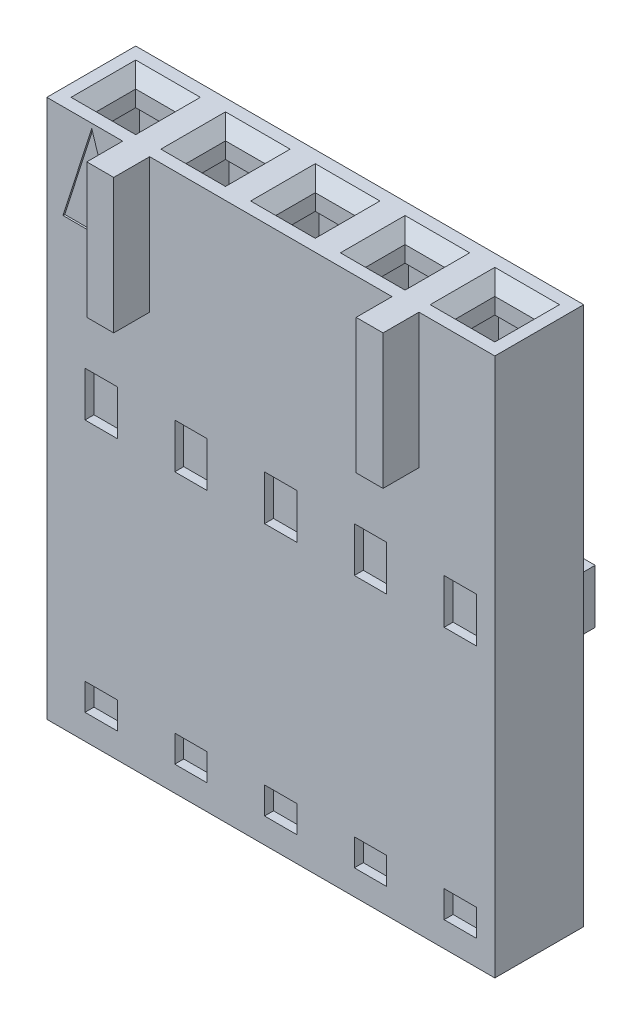
from build123d import *

# Parameters (mm, degrees)
SKETCH1_W            = 12.6746
SKETCH1_H            = 15.24
BOSS_EXTRUDE1_DEPTH  = 2.514600001
SKETCH2_W            = 1.8542
SKETCH2_H            = 1.778
CUT_EXTRUDE1_DEPTH   = 8.636
SKETCH3_W            = 1.8542
SKETCH3_H            = 1.778
CUT_EXTRUDE2_DEPTH   = 8.636
SKETCH4_W            = 1.8542
SKETCH4_H            = 1.778
CUT_EXTRUDE3_DEPTH   = 8.636
SKETCH5_W            = 1.8542
SKETCH5_H            = 1.778
CUT_EXTRUDE4_DEPTH   = 8.636
SKETCH6_W            = 1.8542
SKETCH6_H            = 1.778
CUT_EXTRUDE5_DEPTH   = 8.636
CHAMFER1_SIZE        = 0.0762
CHAMFER1_SIZE2       = 0.254
CHAMFER2_SIZE        = 0.0762
CHAMFER2_SIZE2       = 0.254
CHAMFER3_SIZE        = 0.0762
CHAMFER3_SIZE2       = 0.254
CHAMFER4_SIZE        = 0.0762
CHAMFER4_SIZE2       = 0.254
CHAMFER5_SIZE        = 0.0762
CHAMFER5_SIZE2       = 0.254
CUT_EXTRUDE6_REACH   = 12.213
SKETCH8_W            = 1.4224
SKETCH8_H            = 1.6256
CUT_EXTRUDE7_DEPTH   = 5.7912
SKETCH9_W            = 1.4224
SKETCH9_H            = 1.6256
CUT_EXTRUDE8_DEPTH   = 5.7912
SKETCH10_W           = 1.4224
SKETCH10_H           = 1.6256
CUT_EXTRUDE9_DEPTH   = 5.7912
SKETCH11_W           = 1.4224
SKETCH11_H           = 1.6256
CUT_EXTRUDE10_DEPTH  = 5.7912
SKETCH12_W           = 1.4224
SKETCH12_H           = 1.6256
CUT_EXTRUDE11_DEPTH  = 5.7912
SKETCH13_W           = 1.1176
SKETCH13_H           = 1.1176
CUT_EXTRUDE12_DEPTH  = 16.807791573
SKETCH14_W           = 1.1176
SKETCH14_H           = 1.1176
CUT_EXTRUDE13_DEPTH  = 16.807791573
SKETCH15_W           = 1.1176
SKETCH15_H           = 1.1176
CUT_EXTRUDE14_DEPTH  = 16.807791573
SKETCH16_W           = 1.1176
SKETCH16_H           = 1.1176
CUT_EXTRUDE15_DEPTH  = 16.807791573
SKETCH17_W           = 1.1176
SKETCH17_H           = 1.1176
CUT_EXTRUDE16_DEPTH  = 16.807791573
BOSS_EXTRUDE2_DEPTH  = 4.7498
BOSS_EXTRUDE3_DEPTH  = 1.549215566
CHAMFER6_SIZE        = 3.689417857
CHAMFER6_SIZE2       = 0.617363155
DRAFT1_ANGLE         = 3.38
CUT_EXTRUDE17_REACH  = 13.516
CUT_EXTRUDE18_REACH  = 13.516
CUT_EXTRUDE19_REACH  = 13.384
CUT_EXTRUDE20_REACH  = 13.384
BOSS_EXTRUDE4_REACH  = 13.023
SKETCH24_W           = 2.032
SKETCH24_H           = 0.5588
CUT_EXTRUDE21_DEPTH  = 0.762
CHAMFER7_SIZE        = 0.508
CHAMFER8_SIZE        = 0.508
CHAMFER9_SIZE        = 0.3556
CHAMFER10_SIZE       = 0.3556
CHAMFER11_SIZE       = 0.3556
CHAMFER12_SIZE       = 0.3556
CHAMFER13_SIZE       = 0.3556
FILLET1_R            = 0.8128
DRAFT2_ANGLE         = 43.044366599
SKETCH26_W           = 0.9271
SKETCH26_H           = 3.937
BOSS_EXTRUDE5_DEPTH  = 2.921
SKETCH27_W           = 0.9271
SKETCH27_H           = 3.937
BOSS_EXTRUDE6_DEPTH  = 2.921
BOSS_EXTRUDE7_DEPTH  = 1.2573
BOSS_EXTRUDE8_DEPTH  = 1.2573
SKETCH30_W           = 1.2573
SKETCH30_H           = 0.6858
CUT_EXTRUDE22_DEPTH  = 2.413
SKETCH31_W           = 1.2573
SKETCH31_H           = 0.6858
CUT_EXTRUDE23_DEPTH  = 2.413
CUT_EXTRUDE24_REACH  = 12.801
SKETCH32_W           = 0.9271
SKETCH32_H           = 2.413
CUT_EXTRUDE25_REACH  = 12.801
SKETCH33_W           = 0.9271
SKETCH33_H           = 2.413
DRAFT3_ANGLE         = 14.743562836
DRAFT4_ANGLE         = 14.743562836
CUT_EXTRUDE26_DEPTH  = 2.032
CUT_EXTRUDE27_DEPTH  = 2.032
CUT_EXTRUDE28_DEPTH  = 2.032
SKETCH37_W           = 1.27
SKETCH37_H           = 0.3683
CUT_EXTRUDE29_DEPTH  = 1.016
SKETCH38_W           = 1.27
SKETCH38_H           = 0.3683
CUT_EXTRUDE30_DEPTH  = 1.016
SKETCH39_W           = 1.27
SKETCH39_H           = 0.3683
CUT_EXTRUDE31_DEPTH  = 1.016
SKETCH40_W           = 1.27
SKETCH40_H           = 0.3683
CUT_EXTRUDE32_DEPTH  = 1.016
SKETCH41_W           = 1.27
SKETCH41_H           = 0.3683
CUT_EXTRUDE33_DEPTH  = 1.016
SKETCH42_W           = 0.9144
SKETCH42_H           = 0.762
CUT_EXTRUDE34_DEPTH  = 0.254
SKETCH43_W           = 0.9144
SKETCH43_H           = 0.762
CUT_EXTRUDE35_DEPTH  = 0.254
SKETCH44_W           = 0.9144
SKETCH44_H           = 0.762
CUT_EXTRUDE36_DEPTH  = 0.254
SKETCH45_W           = 0.9144
SKETCH45_H           = 0.762
CUT_EXTRUDE37_DEPTH  = 0.254
SKETCH46_W           = 0.9144
SKETCH46_H           = 0.762
CUT_EXTRUDE38_DEPTH  = 0.254
SKETCH47_W           = 0.9144
SKETCH47_H           = 1.27
CUT_EXTRUDE39_DEPTH  = 0.254
LPATTERN1_COUNT      = 5
LPATTERN1_PITCH      = 2.54
SKETCH48_W           = 0.762
SKETCH48_H           = 3.81
BOSS_EXTRUDE9_DEPTH  = 1.016
SKETCH49_W           = 0.762
SKETCH49_H           = 3.81
BOSS_EXTRUDE10_DEPTH = 1.016


with BuildPart() as part:
    # Sketch1 → Boss-Extrude1 (new body)
    with BuildSketch(Plane(origin=(0, 0, -1.2573), x_dir=(-1, 0, 0), z_dir=(0, 0, -1))):
        Rectangle(SKETCH1_W, SKETCH1_H)
    extrude(amount=-BOSS_EXTRUDE1_DEPTH)

    # Sketch2 → Cut-Extrude1 (cut)
    with BuildSketch(Plane.XZ.offset(7.62)):
        with Locations((5.08, 0)):
            Rectangle(SKETCH2_W, SKETCH2_H)
    extrude(amount=-CUT_EXTRUDE1_DEPTH, mode=Mode.SUBTRACT)

    # Sketch3 → Cut-Extrude2 (cut)
    with BuildSketch(Plane.XZ.offset(7.62)):
        with Locations((2.54, 0)):
            Rectangle(SKETCH3_W, SKETCH3_H)
    extrude(amount=-CUT_EXTRUDE2_DEPTH, mode=Mode.SUBTRACT)

    # Sketch4 → Cut-Extrude3 (cut)
    with BuildSketch(Plane.XZ.offset(7.62)):
        Rectangle(SKETCH4_W, SKETCH4_H)
    extrude(amount=-CUT_EXTRUDE3_DEPTH, mode=Mode.SUBTRACT)

    # Sketch5 → Cut-Extrude4 (cut)
    with BuildSketch(Plane.XZ.offset(7.62)):
        with Locations((-2.54, 0)):
            Rectangle(SKETCH5_W, SKETCH5_H)
    extrude(amount=-CUT_EXTRUDE4_DEPTH, mode=Mode.SUBTRACT)

    # Sketch6 → Cut-Extrude5 (cut)
    with BuildSketch(Plane.XZ.offset(7.62)):
        with Locations((-5.08, 0)):
            Rectangle(SKETCH6_W, SKETCH6_H)
    extrude(amount=-CUT_EXTRUDE5_DEPTH, mode=Mode.SUBTRACT)

    # Chamfer1
    chamfer1_edges = [part.edges().sort_by_distance(p)[0] for p in [
        (5.08, 1.016, -0.889),
        (6.0071, 1.016, 0),
        (4.1529, 1.016, 0),
        (5.08, 1.016, 0.889),
    ]]
    chamfer1_side = [part.faces().sort_by_distance(p)[0] for p in [
        (5.08, 1.016, 0),
    ]]
    chamfer(chamfer1_edges, length=CHAMFER1_SIZE, length2=CHAMFER1_SIZE2, reference=chamfer1_side[0])

    # Chamfer2
    chamfer2_edges = [part.edges().sort_by_distance(p)[0] for p in [
        (2.54, 1.016, -0.889),
        (3.4671, 1.016, 0),
        (1.6129, 1.016, 0),
        (2.54, 1.016, 0.889),
    ]]
    chamfer2_side = [part.faces().sort_by_distance(p)[0] for p in [
        (2.54, 1.016, 0),
    ]]
    chamfer(chamfer2_edges, length=CHAMFER2_SIZE, length2=CHAMFER2_SIZE2, reference=chamfer2_side[0])

    # Chamfer3
    chamfer3_edges = [part.edges().sort_by_distance(p)[0] for p in [
        (0, 1.016, -0.889),
        (0.9271, 1.016, 0),
        (-0.9271, 1.016, 0),
        (0, 1.016, 0.889),
    ]]
    chamfer3_side = [part.faces().sort_by_distance(p)[0] for p in [
        (0, 1.016, 0),
    ]]
    chamfer(chamfer3_edges, length=CHAMFER3_SIZE, length2=CHAMFER3_SIZE2, reference=chamfer3_side[0])

    # Chamfer4
    chamfer4_edges = [part.edges().sort_by_distance(p)[0] for p in [
        (-2.54, 1.016, -0.889),
        (-1.6129, 1.016, 0),
        (-3.4671, 1.016, 0),
        (-2.54, 1.016, 0.889),
    ]]
    chamfer4_side = [part.faces().sort_by_distance(p)[0] for p in [
        (-2.54, 1.016, 0),
    ]]
    chamfer(chamfer4_edges, length=CHAMFER4_SIZE, length2=CHAMFER4_SIZE2, reference=chamfer4_side[0])

    # Chamfer5
    chamfer5_edges = [part.edges().sort_by_distance(p)[0] for p in [
        (-5.08, 1.016, 0.889),
        (-6.0071, 1.016, 0),
        (-4.1529, 1.016, 0),
        (-5.08, 1.016, -0.889),
    ]]
    chamfer5_side = [part.faces().sort_by_distance(p)[0] for p in [
        (-5.08, 1.016, 0),
    ]]
    chamfer(chamfer5_edges, length=CHAMFER5_SIZE, length2=CHAMFER5_SIZE2, reference=chamfer5_side[0])

    # Sketch7 → Cut-Extrude6 (cut, up to next)
    with BuildSketch(Plane(origin=(0, 0, 1.2065), x_dir=(-1, 0, 0), z_dir=(0, 0, -1)), mode=Mode.PRIVATE) as cut_extrude6_sk1:
        Polygon((4.2545, 4.953), (5.8801, 4.953), (5.0673, 7.493), align=None)
    cut_extrude6_tool1 = extrude(cut_extrude6_sk1.sketch, amount=-CUT_EXTRUDE6_REACH, mode=Mode.PRIVATE) & part.part
    add(cut_extrude6_tool1.solids().sort_by_distance((-5.0673, 5.799667, 1.2065))[0], mode=Mode.SUBTRACT)

    # Sketch8 → Cut-Extrude7 (cut)
    with BuildSketch(Plane.XZ.offset(-1.016)):
        with Locations((-5.08, 0)):
            Rectangle(SKETCH8_W, SKETCH8_H)
    extrude(amount=-CUT_EXTRUDE7_DEPTH, mode=Mode.SUBTRACT)

    # Sketch9 → Cut-Extrude8 (cut)
    with BuildSketch(Plane.XZ.offset(-1.016)):
        with Locations((-2.54, 0)):
            Rectangle(SKETCH9_W, SKETCH9_H)
    extrude(amount=-CUT_EXTRUDE8_DEPTH, mode=Mode.SUBTRACT)

    # Sketch10 → Cut-Extrude9 (cut)
    with BuildSketch(Plane.XZ.offset(-1.016)):
        Rectangle(SKETCH10_W, SKETCH10_H)
    extrude(amount=-CUT_EXTRUDE9_DEPTH, mode=Mode.SUBTRACT)

    # Sketch11 → Cut-Extrude10 (cut)
    with BuildSketch(Plane.XZ.offset(-1.016)):
        with Locations((2.54, 0)):
            Rectangle(SKETCH11_W, SKETCH11_H)
    extrude(amount=-CUT_EXTRUDE10_DEPTH, mode=Mode.SUBTRACT)

    # Sketch12 → Cut-Extrude11 (cut)
    with BuildSketch(Plane.XZ.offset(-1.016)):
        with Locations((5.08, 0)):
            Rectangle(SKETCH12_W, SKETCH12_H)
    extrude(amount=-CUT_EXTRUDE11_DEPTH, mode=Mode.SUBTRACT)

    # Sketch13 → Cut-Extrude12 (cut, through all)
    with BuildSketch(Plane.XZ.offset(-6.8072)):
        with Locations((-5.08, 0)):
            Rectangle(SKETCH13_W, SKETCH13_H)
    extrude(amount=-CUT_EXTRUDE12_DEPTH, mode=Mode.SUBTRACT)

    # Sketch14 → Cut-Extrude13 (cut, through all)
    with BuildSketch(Plane.XZ.offset(-6.8072)):
        with Locations((-2.54, 0)):
            Rectangle(SKETCH14_W, SKETCH14_H)
    extrude(amount=-CUT_EXTRUDE13_DEPTH, mode=Mode.SUBTRACT)

    # Sketch15 → Cut-Extrude14 (cut, through all)
    with BuildSketch(Plane.XZ.offset(-6.8072)):
        Rectangle(SKETCH15_W, SKETCH15_H)
    extrude(amount=-CUT_EXTRUDE14_DEPTH, mode=Mode.SUBTRACT)

    # Sketch16 → Cut-Extrude15 (cut, through all)
    with BuildSketch(Plane.XZ.offset(-6.8072)):
        with Locations((2.54, 0)):
            Rectangle(SKETCH16_W, SKETCH16_H)
    extrude(amount=-CUT_EXTRUDE15_DEPTH, mode=Mode.SUBTRACT)

    # Sketch17 → Cut-Extrude16 (cut, through all)
    with BuildSketch(Plane.XZ.offset(-6.8072)):
        with Locations((5.08, 0)):
            Rectangle(SKETCH17_W, SKETCH17_H)
    extrude(amount=-CUT_EXTRUDE16_DEPTH, mode=Mode.SUBTRACT)

    # Sketch18 → Boss-Extrude2 (add)
    with BuildSketch(Plane(origin=(2.3749, 0, 0), x_dir=(0, 0, -1), z_dir=(1, 0, 0))):
        with BuildLine():
            Line((2.629084434, -5.207), (2.629084434, -4.953))
            Line((2.629084434, -4.953), (2.629084434, -4.445))
            Line((2.629084434, -4.445), (2.629084434, -4.191))
            Line((2.629084434, -4.191), (2.629084434, -3.683))
            Line((2.629084434, -3.683), (2.629084434, -3.429))
            Line((2.629084434, -3.429), (2.629084434, -3.048))
            Line((2.629084434, -3.048), (2.629084434, 5.715))
            Line((2.629084434, 5.715), (1.2573, 5.715))
            Line((1.2573, 5.715), (1.2573, 4.3942))
            ThreePointArc((1.2573, 4.3942), (1.553110903, 4.698867419), (1.866369791, 4.412170374))
            Line((1.866369791, 4.412170374), (2.434484307, -5.207))
            Line((2.434484307, -5.207), (2.629084434, -5.207))
        make_face()
    extrude(amount=-BOSS_EXTRUDE2_DEPTH)

    # Sketch19 → Boss-Extrude3 (add)
    with BuildSketch(Plane(origin=(0, 0, -2.629084434), x_dir=(-1, 0, 0), z_dir=(0, 0, -1))):
        Polygon((2.3749, -3.683), (2.3749, -4.191), (2.3749, -4.445), (2.3749, -4.953), (2.3749, -5.207), (1.016, -5.207), (-1.016, -5.207), (-2.3749, -5.207), (-2.3749, -4.953), (-2.3749, -4.445), (-2.3749, -4.191), (-2.3749, -3.683), (-2.3749, -3.429), (-2.3749, -3.048), (-2.3749, -1.524), (-1.016, -1.524), (1.016, -1.524), (2.3749, -1.524), (2.3749, -3.048), (2.3749, -3.429), align=None)
    extrude(amount=BOSS_EXTRUDE3_DEPTH)

    # Chamfer6
    chamfer6_edges = [part.edges().sort_by_distance(p)[0] for p in [
        (0, -5.207, -2.434484307),
    ]]
    chamfer6_side = [part.faces().sort_by_distance(p)[0] for p in [
        (0, -0.397414813, -2.150427049),
    ]]
    chamfer(chamfer6_edges, length=CHAMFER6_SIZE, length2=CHAMFER6_SIZE2, reference=chamfer6_side[0])

    # Draft1
    draft1_faces = [part.faces().sort_by_distance(p)[0] for p in [
        (0, 2.0955, -2.629084434),
    ]]
    draft(draft1_faces, Plane(origin=(-2.3749, 5.715, -2.629084434), x_dir=(0, 0, 1), z_dir=(0, 1, 0)), DRAFT1_ANGLE)

    # Sketch20 → Cut-Extrude17 (cut, up to next)
    with BuildSketch(Plane(origin=(1.2192, 0, 0), x_dir=(0, -1, 0), z_dir=(-1, 0, 0)), mode=Mode.PRIVATE) as cut_extrude17_sk1:
        with BuildLine():
            Line((-5.715, -2.629084434), (-1.778, -2.861606238))
            Line((-1.778, -2.861606238), (-1.778, -2.021945622))
            Line((-1.778, -2.021945622), (-4.412170374, -1.866369791))
            ThreePointArc((-4.412170374, -1.866369791), (-4.698867419, -1.553110903), (-4.3942, -1.2573))
            Line((-4.3942, -1.2573), (-5.715, -1.2573))
            Line((-5.715, -1.2573), (-5.715, -2.629084434))
        make_face()
    cut_extrude17_tool1 = extrude(cut_extrude17_sk1.sketch, amount=-CUT_EXTRUDE17_REACH, mode=Mode.PRIVATE) & part.part
    add(cut_extrude17_tool1.solids().sort_by_distance((1.2192, 3.966731, -2.203229))[0], mode=Mode.SUBTRACT)

    # Sketch21 → Cut-Extrude18 (cut, up to next)
    with BuildSketch(Plane(origin=(-1.2192, 0, 0), x_dir=(0, 0, -1), z_dir=(1, 0, 0)), mode=Mode.PRIVATE) as cut_extrude18_sk1:
        with BuildLine():
            Line((2.021945622, 1.778), (2.861606238, 1.778))
            Line((2.861606238, 1.778), (2.629084434, 5.715))
            Line((2.629084434, 5.715), (1.2573, 5.715))
            Line((1.2573, 5.715), (1.2573, 4.3942))
            ThreePointArc((1.2573, 4.3942), (1.553110903, 4.698867419), (1.866369791, 4.412170374))
            Line((1.866369791, 4.412170374), (2.021945622, 1.778))
        make_face()
    cut_extrude18_tool1 = extrude(cut_extrude18_sk1.sketch, amount=-CUT_EXTRUDE18_REACH, mode=Mode.PRIVATE) & part.part
    add(cut_extrude18_tool1.solids().sort_by_distance((-1.2192, 3.966731, -2.203229))[0], mode=Mode.SUBTRACT)

    # Sketch22 → Cut-Extrude19 (cut, up to next)
    with BuildSketch(Plane(origin=(1.016, 0, 0), x_dir=(0, -1, 0), z_dir=(-1, 0, 0)), mode=Mode.PRIVATE) as cut_extrude19_sk1:
        Polygon((3.048000001, -2.562432966), (3.048000001, -3.146632966), (1.524, -3.056624525), (1.524, -4.1783), (3.048, -4.1783), (3.429, -4.1783), (3.683, -4.1783), (4.191, -4.1783), (4.445, -4.1783), (4.953, -4.1783), (5.207000001, -4.1783), (5.207000001, -3.051847462), align=None)
    cut_extrude19_tool1 = extrude(cut_extrude19_sk1.sketch, amount=-CUT_EXTRUDE19_REACH, mode=Mode.PRIVATE) & part.part
    add(cut_extrude19_tool1.solids().sort_by_distance((1.016, -3.425691, -3.540435))[0], mode=Mode.SUBTRACT)

    # Sketch23 → Cut-Extrude20 (cut, up to next)
    with BuildSketch(Plane(origin=(-1.016, 0, 0), x_dir=(0, 0, -1), z_dir=(1, 0, 0)), mode=Mode.PRIVATE) as cut_extrude20_sk1:
        Polygon((4.1783, -1.524000001), (3.056624525, -1.524000001), (3.146632966, -3.048), (2.562432966, -3.048), (3.051847462, -5.207), (4.1783, -5.207), (4.1783, -4.953), (4.1783, -4.445), (4.1783, -4.191), (4.1783, -3.683), (4.1783, -3.429), (4.1783, -3.048), align=None)
    cut_extrude20_tool1 = extrude(cut_extrude20_sk1.sketch, amount=-CUT_EXTRUDE20_REACH, mode=Mode.PRIVATE) & part.part
    add(cut_extrude20_tool1.solids().sort_by_distance((-1.016, -3.425691, -3.540435))[0], mode=Mode.SUBTRACT)

    # Sketch24 → Boss-Extrude4 (add, up to next)
    with BuildSketch(Plane(origin=(0, 0, -3.5687), x_dir=(-1, 0, 0), z_dir=(0, 0, -1)), mode=Mode.PRIVATE) as boss_extrude4_sk1:
        with Locations((0, 0.8382)):
            Rectangle(SKETCH24_W, SKETCH24_H)
    boss_extrude4_tool1 = extrude(boss_extrude4_sk1.sketch, amount=-BOSS_EXTRUDE4_REACH, mode=Mode.PRIVATE) - part.part
    add(boss_extrude4_tool1.solids().sort_by_distance((0, 0.8382, -3.5687))[0])

    # Sketch25 → Cut-Extrude21 (cut)
    with BuildSketch(Plane(origin=(-0.381, 0, 0), x_dir=(0, -1, 0), z_dir=(-1, 0, 0))):
        Polygon((5.207, -3.051847462), (2.159, -2.36090935), (2.159, -3.2893), (5.207, -3.2893), align=None)
    extrude(amount=-CUT_EXTRUDE21_DEPTH, mode=Mode.SUBTRACT)

    # Chamfer7
    chamfer7_edges = [part.edges().sort_by_distance(p)[0] for p in [
        (2.3749, 1.778, -2.44177593),
    ]]
    chamfer(chamfer7_edges, length=CHAMFER7_SIZE)

    # Chamfer8
    chamfer8_edges = [part.edges().sort_by_distance(p)[0] for p in [
        (-2.3749, 1.778, -2.44177593),
    ]]
    chamfer(chamfer8_edges, length=CHAMFER8_SIZE)

    # Chamfer9
    chamfer9_edges = [part.edges().sort_by_distance(p)[0] for p in [
        (5.6388, 7.62, 0),
        (5.08, 7.62, -0.5588),
        (5.08, 7.62, 0.5588),
        (4.5212, 7.62, 0),
    ]]
    chamfer(chamfer9_edges, length=CHAMFER9_SIZE)

    # Chamfer10
    chamfer10_edges = [part.edges().sort_by_distance(p)[0] for p in [
        (3.0988, 7.62, 0),
        (2.54, 7.62, -0.5588),
        (2.54, 7.62, 0.5588),
        (1.9812, 7.62, 0),
    ]]
    chamfer(chamfer10_edges, length=CHAMFER10_SIZE)

    # Chamfer11
    chamfer11_edges = [part.edges().sort_by_distance(p)[0] for p in [
        (0.5588, 7.62, 0),
        (0, 7.62, -0.5588),
        (0, 7.62, 0.5588),
        (-0.5588, 7.62, 0),
    ]]
    chamfer(chamfer11_edges, length=CHAMFER11_SIZE)

    # Chamfer12
    chamfer12_edges = [part.edges().sort_by_distance(p)[0] for p in [
        (-1.9812, 7.62, 0),
        (-2.54, 7.62, -0.5588),
        (-2.54, 7.62, 0.5588),
        (-3.0988, 7.62, 0),
    ]]
    chamfer(chamfer12_edges, length=CHAMFER12_SIZE)

    # Chamfer13
    chamfer13_edges = [part.edges().sort_by_distance(p)[0] for p in [
        (-4.5212, 7.62, 0),
        (-5.08, 7.62, -0.5588),
        (-5.08, 7.62, 0.5588),
        (-5.6388, 7.62, 0),
    ]]
    chamfer(chamfer13_edges, length=CHAMFER13_SIZE)

    # Fillet1
    fillet1_edges = [part.edges().sort_by_distance(p)[0] for p in [
        (0, 5.715, -2.629084434),
    ]]
    fillet(fillet1_edges, radius=FILLET1_R)

    # Draft2
    draft2_faces = [part.faces().sort_by_distance(p)[0] for p in [
        (0, 1.1176, -3.234654948),
    ]]
    draft(draft2_faces, Plane(origin=(0, 0, -3.5687), x_dir=(-1, 0, 0), z_dir=(0, 0, -1)), DRAFT2_ANGLE)

    # Sketch26 → Boss-Extrude5 (add)
    with BuildSketch(Plane(origin=(0, 0, -1.2573), x_dir=(-1, 0, 0), z_dir=(0, 0, -1))):
        with Locations((3.2766, -3.4925)):
            Rectangle(SKETCH26_W, SKETCH26_H)
    extrude(amount=BOSS_EXTRUDE5_DEPTH)

    # Sketch27 → Boss-Extrude6 (add)
    with BuildSketch(Plane(origin=(0, 0, -1.2573), x_dir=(-1, 0, 0), z_dir=(0, 0, -1))):
        with Locations((-3.2766, -3.4925)):
            Rectangle(SKETCH27_W, SKETCH27_H)
    extrude(amount=BOSS_EXTRUDE6_DEPTH)

    # Sketch28 → Boss-Extrude7 (add)
    with BuildSketch(Plane.ZY.offset(-2.81305)):
        Polygon((-4.1783, -3.048), (-4.1783, -1.524), (-3.4925, -1.524), (-3.4925, -3.048), (-3.4925, -5.461000001), (-4.1783, -5.461000001), align=None)
    extrude(amount=BOSS_EXTRUDE7_DEPTH)

    # Sketch29 → Boss-Extrude8 (add)
    with BuildSketch(Plane(origin=(-2.81305, 0, 0), x_dir=(0, 0, -1), z_dir=(1, 0, 0))):
        Polygon((3.4925, -1.524), (4.1783, -1.524), (4.1783, -3.048), (4.1783, -5.461000001), (3.4925, -5.461000001), (3.4925, -3.048), align=None)
    extrude(amount=BOSS_EXTRUDE8_DEPTH)

    # Sketch30 → Cut-Extrude22 (cut)
    with BuildSketch(Plane.XZ.offset(5.461)):
        with Locations((-2.1844, -3.8354)):
            Rectangle(SKETCH30_W, SKETCH30_H)
    extrude(amount=-CUT_EXTRUDE22_DEPTH, mode=Mode.SUBTRACT)

    # Sketch31 → Cut-Extrude23 (cut)
    with BuildSketch(Plane.XZ.offset(5.461)):
        with Locations((2.1844, -3.8354)):
            Rectangle(SKETCH31_W, SKETCH31_H)
    extrude(amount=-CUT_EXTRUDE23_DEPTH, mode=Mode.SUBTRACT)

    # Sketch32 → Cut-Extrude24 (cut, up to next)
    with BuildSketch(Plane.XY.offset(-3.0353), mode=Mode.PRIVATE) as cut_extrude24_sk1:
        with Locations((-3.2766, -4.2545)):
            Rectangle(SKETCH32_W, SKETCH32_H)
    cut_extrude24_tool1 = extrude(cut_extrude24_sk1.sketch, amount=-CUT_EXTRUDE24_REACH, mode=Mode.PRIVATE) & part.part
    add(cut_extrude24_tool1.solids().sort_by_distance((-3.2766, -4.2545, -3.0353))[0], mode=Mode.SUBTRACT)

    # Sketch33 → Cut-Extrude25 (cut, up to next)
    with BuildSketch(Plane.XY.offset(-3.0353), mode=Mode.PRIVATE) as cut_extrude25_sk1:
        with Locations((3.2766, -4.2545)):
            Rectangle(SKETCH33_W, SKETCH33_H)
    cut_extrude25_tool1 = extrude(cut_extrude25_sk1.sketch, amount=-CUT_EXTRUDE25_REACH, mode=Mode.PRIVATE) & part.part
    add(cut_extrude25_tool1.solids().sort_by_distance((3.2766, -4.2545, -3.0353))[0], mode=Mode.SUBTRACT)

    # Draft3
    draft3_faces = [part.faces().sort_by_distance(p)[0] for p in [
        (-3.2766, -4.2545, -3.0353),
    ]]
    draft(draft3_faces, Plane(origin=(0, -3.048, 0), x_dir=(0, 0, -1), z_dir=(0, -1, 0)), DRAFT3_ANGLE)

    # Draft4
    draft4_faces = [part.faces().sort_by_distance(p)[0] for p in [
        (3.2766, -4.2545, -3.0353),
    ]]
    draft(draft4_faces, Plane(origin=(0, -3.048, 0), x_dir=(0, 0, -1), z_dir=(0, -1, 0)), DRAFT4_ANGLE)

    # Sketch34 → Cut-Extrude26 (cut)
    with BuildSketch(Plane.ZY.offset(1.016)):
        Polygon((-4.1783, -3.429), (-3.9878, -3.048), (-4.1783, -3.048), align=None)
    extrude(amount=-CUT_EXTRUDE26_DEPTH, mode=Mode.SUBTRACT)

    # Sketch35 → Cut-Extrude27 (cut)
    with BuildSketch(Plane.ZY.offset(1.016)):
        Polygon((-4.1783, -4.191), (-3.9243, -4.064), (-3.9243, -3.81), (-4.1783, -3.683), align=None)
    extrude(amount=-CUT_EXTRUDE27_DEPTH, mode=Mode.SUBTRACT)

    # Sketch36 → Cut-Extrude28 (cut)
    with BuildSketch(Plane.ZY.offset(1.016)):
        Polygon((-4.1783, -4.953), (-3.9243, -4.826), (-3.9243, -4.572), (-4.1783, -4.445), align=None)
    extrude(amount=-CUT_EXTRUDE28_DEPTH, mode=Mode.SUBTRACT)

    # Sketch37 → Cut-Extrude29 (cut)
    with BuildSketch(Plane.XZ.offset(7.62)):
        with Locations((-5.0927, -1.07315)):
            Rectangle(SKETCH37_W, SKETCH37_H)
    extrude(amount=-CUT_EXTRUDE29_DEPTH, mode=Mode.SUBTRACT)

    # Sketch38 → Cut-Extrude30 (cut)
    with BuildSketch(Plane.XZ.offset(7.62)):
        with Locations((-2.5527, -1.07315)):
            Rectangle(SKETCH38_W, SKETCH38_H)
    extrude(amount=-CUT_EXTRUDE30_DEPTH, mode=Mode.SUBTRACT)

    # Sketch39 → Cut-Extrude31 (cut)
    with BuildSketch(Plane.XZ.offset(7.62)):
        with Locations((-0.0127, -1.07315)):
            Rectangle(SKETCH39_W, SKETCH39_H)
    extrude(amount=-CUT_EXTRUDE31_DEPTH, mode=Mode.SUBTRACT)

    # Sketch40 → Cut-Extrude32 (cut)
    with BuildSketch(Plane.XZ.offset(7.62)):
        with Locations((2.5273, -1.07315)):
            Rectangle(SKETCH40_W, SKETCH40_H)
    extrude(amount=-CUT_EXTRUDE32_DEPTH, mode=Mode.SUBTRACT)

    # Sketch41 → Cut-Extrude33 (cut)
    with BuildSketch(Plane.XZ.offset(7.62)):
        with Locations((5.0673, -1.07315)):
            Rectangle(SKETCH41_W, SKETCH41_H)
    extrude(amount=-CUT_EXTRUDE33_DEPTH, mode=Mode.SUBTRACT)

    # Sketch42 → Cut-Extrude34 (cut)
    with BuildSketch(Plane.XY.offset(1.257300001)):
        with Locations((-4.8006, -6.5278)):
            Rectangle(SKETCH42_W, SKETCH42_H)
    extrude(amount=-CUT_EXTRUDE34_DEPTH, mode=Mode.SUBTRACT)

    # Sketch43 → Cut-Extrude35 (cut)
    with BuildSketch(Plane.XY.offset(1.257300001)):
        with Locations((-2.2606, -6.5278)):
            Rectangle(SKETCH43_W, SKETCH43_H)
    extrude(amount=-CUT_EXTRUDE35_DEPTH, mode=Mode.SUBTRACT)

    # Sketch44 → Cut-Extrude36 (cut)
    with BuildSketch(Plane.XY.offset(1.257300001)):
        with Locations((0.2794, -6.5278)):
            Rectangle(SKETCH44_W, SKETCH44_H)
    extrude(amount=-CUT_EXTRUDE36_DEPTH, mode=Mode.SUBTRACT)

    # Sketch45 → Cut-Extrude37 (cut)
    with BuildSketch(Plane.XY.offset(1.257300001)):
        with Locations((2.8194, -6.5278)):
            Rectangle(SKETCH45_W, SKETCH45_H)
    extrude(amount=-CUT_EXTRUDE37_DEPTH, mode=Mode.SUBTRACT)

    # Sketch46 → Cut-Extrude38 (cut)
    with BuildSketch(Plane.XY.offset(1.257300001)):
        with Locations((5.3594, -6.5278)):
            Rectangle(SKETCH46_W, SKETCH46_H)
    extrude(amount=-CUT_EXTRUDE38_DEPTH, mode=Mode.SUBTRACT)

    # Sketch47 → Cut-Extrude39 (cut)
    with BuildSketch(Plane.XY.offset(1.257300001)):
        with Locations((-4.8006, 0.889)):
            Rectangle(SKETCH47_W, SKETCH47_H)
    cut_extrude39 = extrude(amount=-CUT_EXTRUDE39_DEPTH, mode=Mode.SUBTRACT)

    # LPattern1: Cut-Extrude39 ×5
    with Locations(*[(i * LPATTERN1_PITCH, 0, 0) for i in range(1, LPATTERN1_COUNT)]):
        add(cut_extrude39, mode=Mode.SUBTRACT)

    # Sketch48 → Boss-Extrude9 (add)
    with BuildSketch(Plane.XY.offset(1.257300001)):
        with Locations((3.81, 5.715)):
            Rectangle(SKETCH48_W, SKETCH48_H)
    extrude(amount=BOSS_EXTRUDE9_DEPTH)

    # Sketch49 → Boss-Extrude10 (add)
    with BuildSketch(Plane.XY.offset(1.257300001)):
        with Locations((-3.81, 5.715)):
            Rectangle(SKETCH49_W, SKETCH49_H)
    extrude(amount=BOSS_EXTRUDE10_DEPTH)


solid = part.part
